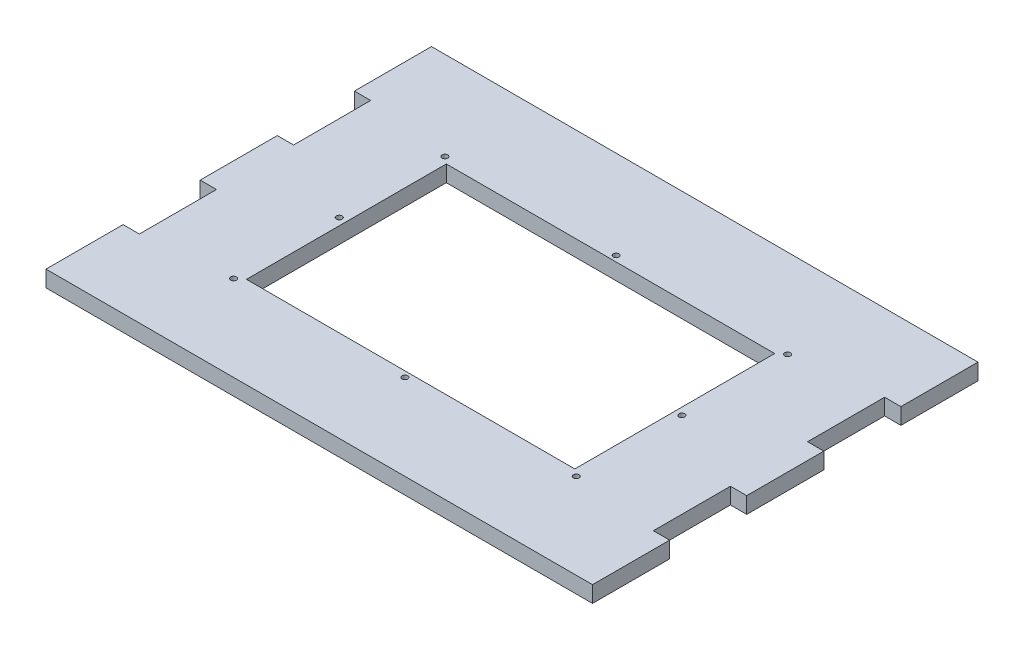
from build123d import *

# Parameters (mm, degrees)
SKETCH3_W           = 192
SKETCH3_H           = 135
BOSS_EXTRUDE1_DEPTH = 5.7
SKETCH9_W           = 115
SKETCH9_H           = 70
CUT_EXTRUDE2_DEPTH  = 47
SKETCH12_R          = 1
CUT_EXTRUDE3_DEPTH  = 37
CUT_EXTRUDE4_DEPTH  = 11


with BuildPart() as part:
    # Sketch3 → Boss-Extrude1 (new body)
    with BuildSketch(Plane(origin=(0, 0, 0), x_dir=(1, 0, 0), z_dir=(0, 1, 0))):
        with Locations((90, 53.5)):
            Rectangle(SKETCH3_W, SKETCH3_H)
    extrude(amount=BOSS_EXTRUDE1_DEPTH)

    # Sketch9 → Cut-Extrude2 (cut)
    with BuildSketch(Plane(origin=(0, 0, 0), x_dir=(1, 0, 0), z_dir=(0, 1, 0))):
        with Locations((90, 53)):
            Rectangle(SKETCH9_W, SKETCH9_H)
    extrude(amount=CUT_EXTRUDE2_DEPTH, mode=Mode.SUBTRACT)

    # Sketch12 → Cut-Extrude3 (cut)
    with BuildSketch(Plane(origin=(0, 0, 0), x_dir=(1, 0, 0), z_dir=(0, 1, 0))):
        with Locations((30, 90)):
            Circle(SKETCH12_R)
        with Locations((30, 53)):
            Circle(SKETCH12_R)
        with Locations((30, 16)):
            Circle(SKETCH12_R)
        with Locations((90, 16)):
            Circle(SKETCH12_R)
        with Locations((150, 16)):
            Circle(SKETCH12_R)
        with Locations((150, 53)):
            Circle(SKETCH12_R)
        with Locations((150, 90)):
            Circle(SKETCH12_R)
        with Locations((90, 90)):
            Circle(SKETCH12_R)
    extrude(amount=CUT_EXTRUDE3_DEPTH, mode=Mode.SUBTRACT)

    # Sketch13 → Cut-Extrude4 (cut)
    with BuildSketch(Plane(origin=(0, 0, 0), x_dir=(1, 0, 0), z_dir=(0, 1, 0))):
        Polygon((-5.7, 121), (-5.7, 94), (0, 94), (0, 67), (-5.7, 67), (-5.7, 40), (0, 40), (0, 13), (-5.7, 13), (-5.7, -14), (-9.7, -14), (-9.7, 121), align=None)
        Polygon((189.7, 121), (185.7, 121), (185.7, 94), (180, 94), (180, 67), (185.7, 67), (185.7, 40), (180, 40), (180, 13), (185.7, 13), (185.7, -14), (189.7, -14), align=None)
    extrude(amount=CUT_EXTRUDE4_DEPTH, mode=Mode.SUBTRACT)


solid = part.part
